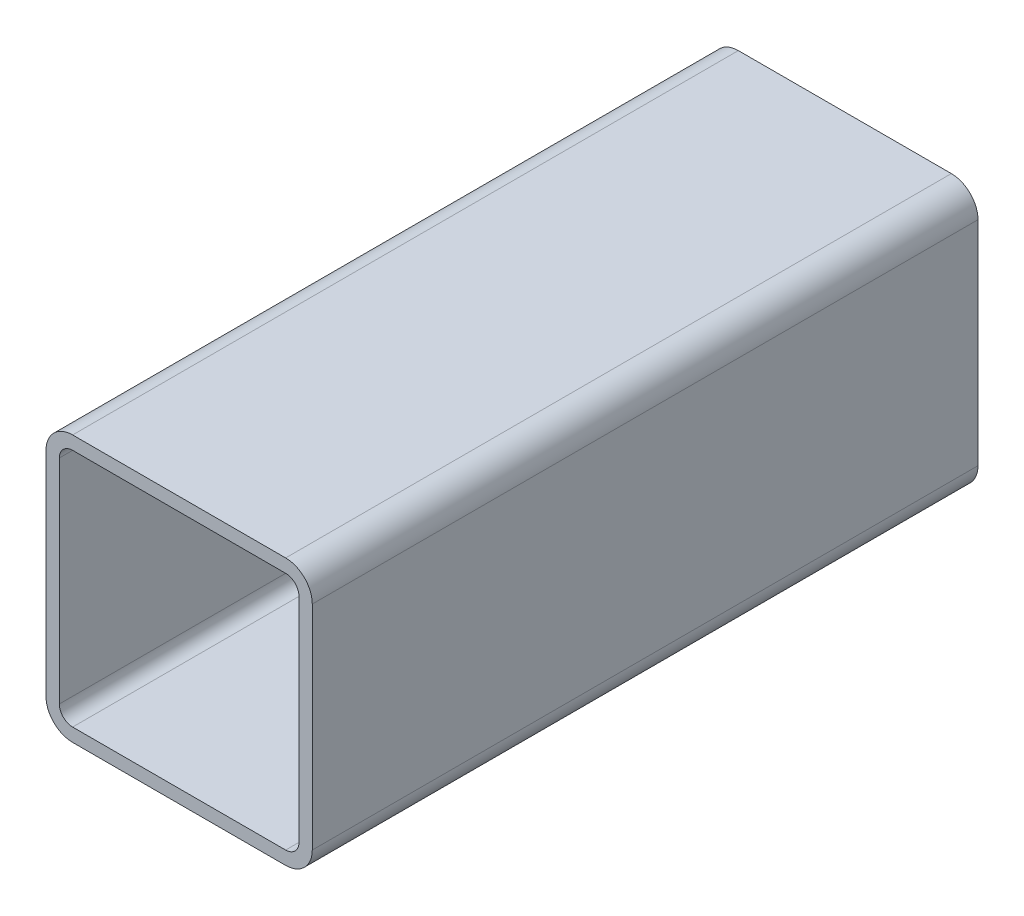
from build123d import *

# Parameters (mm, degrees)
BOSS_EXTRUDE1_DEPTH = 100
CUT_EXTRUDE1_START  = -20
SKETCH2_W           = 0.1
SKETCH2_H           = 60
CUT_EXTRUDE1_DEPTH  = 0.5
CUT_EXTRUDE2_START  = -20
CUT_EXTRUDE2_DEPTH  = 0.5


with BuildPart() as part:
    # Sketch1 → Boss-Extrude1 (new body)
    with BuildSketch(Plane.XY):
        with BuildLine():
            Line((-16, 20), (16, 20))
            ThreePointArc((16, 20), (18.828427125, 18.828427125), (20, 16))
            Line((20, 16), (20, -16))
            ThreePointArc((20, -16), (18.828427125, -18.828427125), (16, -20))
            Line((16, -20), (-16, -20))
            ThreePointArc((-16, -20), (-18.828427125, -18.828427125), (-20, -16))
            Line((-20, -16), (-20, 16))
            ThreePointArc((-20, 16), (-18.828427125, 18.828427125), (-16, 20))
        make_face()
        with BuildLine():
            Line((-18, 16), (-18, -16))
            ThreePointArc((-18, -16), (-17.414213562, -17.414213562), (-16, -18))
            Line((-16, -18), (16, -18))
            ThreePointArc((16, -18), (17.414213562, -17.414213562), (18, -16))
            Line((18, -16), (18, 16))
            ThreePointArc((18, 16), (17.414213562, 17.414213562), (16, 18))
            Line((16, 18), (-16, 18))
            ThreePointArc((-16, 18), (-17.414213562, 17.414213562), (-18, 16))
        make_face(mode=Mode.SUBTRACT)
    extrude(amount=BOSS_EXTRUDE1_DEPTH)

    # Sketch2 → Cut-Extrude1 (cut)
    with BuildSketch(Plane(origin=(0, 0, 0), x_dir=(1, 0, 0), z_dir=(0, 1, 0)).offset(CUT_EXTRUDE1_START)):
        with Locations((0.05, -50)):
            Rectangle(SKETCH2_W, SKETCH2_H)
    extrude(amount=CUT_EXTRUDE1_DEPTH, mode=Mode.SUBTRACT)

    # Sketch3 → Cut-Extrude2 (cut)
    with BuildSketch(Plane(origin=(0, 0, 0), x_dir=(1, 0, 0), z_dir=(0, 1, 0)).offset(CUT_EXTRUDE2_START)):
        Polygon((3.5, -21.813802083), (3.5, -21.166666667), (0, -21.166666667), (0, -21.480769231), (3.141025641, -21.480769231), (3.141025641, -22.019230769), align=None)
        Polygon((3.58974359, -23.679487179), (3.58974359, -23.365384615), (2.557692308, -23.365384615), (2.557692308, -22.916666667), (2.243589744, -22.916666667), (2.243589744, -23.365384615), (0, -23.365384615), (0, -23.679487179), (2.243589744, -23.679487179), (2.243589744, -24.128205128), (2.557692308, -24.128205128), (2.557692308, -23.679487179), align=None)
        with BuildLine():
            Line((2.557692308, -25.564102564), (2.557692308, -25.25))
            Line((2.557692308, -25.25), (2.181189904, -25.25))
            add(Edge.make_bspline(
                [(2.181189904, -25.25), (2.2162494, -25.226814027), (2.283300414, -25.182471034), (2.371922127, -25.108721958), (2.445625727, -25.033203416), (2.503691528, -24.954976239), (2.547533847, -24.874694376), (2.57991674, -24.793692795), (2.59874011, -24.710293521), (2.601287731, -24.654136547), (2.602564103, -24.626001603)],
                knots=[0, 0, 0, 0, 0.000126023, 0.000241017, 0.000345147, 0.000441905, 0.000532273, 0.000618856, 0.000702888, 0.000787259, 0.000787259, 0.000787259, 0.000787259], degree=3))
            add(Edge.make_bspline(
                [(2.602564103, -24.626001603), (2.60140021, -24.604168204), (2.599017547, -24.55947197), (2.581439148, -24.491605855), (2.554439176, -24.421394642), (2.52842766, -24.376085944), (2.514923878, -24.352564103)],
                knots=[0, 0, 0, 0, 6.5445e-05, 0.000133976, 0.000209232, 0.00029048, 0.00029048, 0.00029048, 0.00029048], degree=3))
            Line((2.514923878, -24.352564103), (2.242888622, -24.525040064))
            add(Edge.make_bspline(
                [(2.242888622, -24.525040064), (2.249628888, -24.540149085), (2.262423203, -24.5688289), (2.277565213, -24.610783466), (2.286481129, -24.649464803), (2.287831847, -24.674108361), (2.288461538, -24.685596955)],
                knots=[0, 0, 0, 0, 4.9621e-05, 9.4191e-05, 0.00013366, 0.000168129, 0.000168129, 0.000168129, 0.000168129], degree=3))
            add(Edge.make_bspline(
                [(2.288461538, -24.685596955), (2.286843274, -24.711055975), (2.283571966, -24.76252117), (2.256021695, -24.837971419), (2.21338135, -24.911517288), (2.164408492, -24.969182248), (2.11808863, -25.014173429), (2.077418579, -25.046297324), (2.031846108, -25.075784718), (1.982114631, -25.103953585), (1.927385308, -25.129620274), (1.868201943, -25.153574829), (1.804496858, -25.175233725), (1.760114331, -25.187583965), (1.737379808, -25.193910256)],
                knots=[0, 0, 0, 0, 7.6187e-05, 0.000154012, 0.000238193, 0.000330296, 0.000379883, 0.000431785, 0.000485456, 0.000542593, 0.000603121, 0.000666657, 0.000734059, 0.000804845, 0.000804845, 0.000804845, 0.000804845], degree=3))
            add(Edge.make_bspline(
                [(1.737379808, -25.193910256), (1.717102634, -25.19864265), (1.672190235, -25.209124541), (1.596841711, -25.219316079), (1.507818052, -25.229385597), (1.404871459, -25.236482216), (1.288259015, -25.243060258), (1.15780307, -25.24677034), (1.013369718, -25.249873481), (0.912395365, -25.249956547), (0.859575321, -25.25)],
                knots=[0, 0, 0, 0, 6.2435e-05, 0.000138289, 0.000227871, 0.000331224, 0.000447781, 0.000578258, 0.000722716, 0.000881171, 0.000881171, 0.000881171, 0.000881171], degree=3))
            Line((0.859575321, -25.25), (0, -25.25))
            Line((0, -25.25), (0, -25.564102564))
            Line((0, -25.564102564), (2.557692308, -25.564102564))
        make_face()
        with BuildLine():
            Line((2.557692308, -26.192307692), (0, -26.192307692))
            Line((0, -26.192307692), (0, -26.506410256))
            Line((0, -26.506410256), (0.442407853, -26.506410256))
            add(Edge.make_bspline(
                [(0.442407853, -26.506410256), (0.402357452, -26.541821641), (0.32419859, -26.610927403), (0.222394827, -26.726327388), (0.137553673, -26.848142506), (0.069666853, -26.976784678), (0.018284474, -27.111869012), (-0.017849104, -27.25301028), (-0.041371077, -27.400020375), (-0.04369442, -27.500276192), (-0.044871795, -27.551081731)],
                knots=[0, 0, 0, 0, 0.000160263, 0.000312755, 0.000460372, 0.00060464, 0.000748002, 0.000892888, 0.00104113, 0.001193435, 0.001193435, 0.001193435, 0.001193435], degree=3))
            add(Edge.make_bspline(
                [(-0.044871795, -27.551081731), (-0.043645626, -27.596249807), (-0.041227567, -27.685323254), (-0.022462337, -27.816350566), (0.007657479, -27.942449333), (0.049598139, -28.063699919), (0.10494392, -28.179280753), (0.171919959, -28.289843101), (0.25089654, -28.395644997), (0.341535176, -28.49467431), (0.439877501, -28.585981791), (0.545073941, -28.665866614), (0.655679624, -28.733571603), (0.771663464, -28.789212978), (0.892940677, -28.832271191), (1.019428064, -28.862228057), (1.150915158, -28.880973065), (1.240455063, -28.883389899), (1.285857372, -28.884615385)],
                knots=[0, 0, 0, 0, 0.000135464, 0.00026714, 0.000396211, 0.000523931, 0.000651257, 0.000779917, 0.000911167, 0.001046665, 0.001182119, 0.001313231, 0.001442255, 0.001570516, 0.001698468, 0.001827539, 0.00195991, 0.002096074, 0.002096074, 0.002096074, 0.002096074], degree=3))
            add(Edge.make_bspline(
                [(1.285857372, -28.884615385), (1.330321265, -28.883362718), (1.418223983, -28.880886265), (1.547499942, -28.862428635), (1.672028314, -28.831413909), (1.791347799, -28.78780574), (1.905938937, -28.732134777), (2.014905164, -28.663265415), (2.119913357, -28.583409379), (2.21759609, -28.491126052), (2.307499363, -28.391207915), (2.386667873, -28.284814067), (2.453472192, -28.173271135), (2.507777609, -28.056355459), (2.550931998, -27.934894904), (2.581014763, -27.807966801), (2.598698613, -27.676148367), (2.601263226, -27.586658815), (2.602564103, -27.541266026)],
                knots=[0, 0, 0, 0, 0.000133363, 0.00026365, 0.000390846, 0.000517716, 0.000644083, 0.000772283, 0.00090382, 0.001039238, 0.001174786, 0.001306599, 0.00143646, 0.001564122, 0.001692735, 0.001822488, 0.001954765, 0.002090929, 0.002090929, 0.002090929, 0.002090929], degree=3))
            add(Edge.make_bspline(
                [(2.602564103, -27.541266026), (2.601133352, -27.489064135), (2.598327716, -27.38669869), (2.574730898, -27.236776304), (2.5353558, -27.094818144), (2.481240021, -26.960005945), (2.409860859, -26.832862676), (2.319006253, -26.714953132), (2.210751775, -26.603903603), (2.127359309, -26.539539889), (2.084435096, -26.506410256)],
                knots=[0, 0, 0, 0, 0.00015654, 0.000306968, 0.000453936, 0.000597673, 0.000741774, 0.000889855, 0.001043054, 0.001205551, 0.001205551, 0.001205551, 0.001205551], degree=3))
            Line((2.084435096, -26.506410256), (2.557692308, -26.506410256))
            Line((2.557692308, -26.506410256), (2.557692308, -26.192307692))
        make_face()
        with BuildLine():
            add(Edge.make_bspline(
                [(2.288461538, -27.537059295), (2.286827918, -27.58297366), (2.283603412, -27.673601315), (2.258429663, -27.806644917), (2.216546024, -27.933959833), (2.159260529, -28.054900259), (2.087245119, -28.167589423), (2.000074446, -28.268205619), (1.900520567, -28.357952616), (1.787746484, -28.432153885), (1.668225935, -28.494712937), (1.542337959, -28.537612915), (1.413575056, -28.566159953), (1.326206752, -28.569058087), (1.282351763, -28.570512821)],
                knots=[0, 0, 0, 0, 0.000137677, 0.000271753, 0.000404561, 0.000538791, 0.000672205, 0.000804452, 0.00093703, 0.001072956, 0.001208416, 0.001340569, 0.001470925, 0.001602305, 0.001602305, 0.001602305, 0.001602305], degree=3))
            add(Edge.make_bspline(
                [(1.282351763, -28.570512821), (1.238767492, -28.568630736), (1.151769786, -28.564873945), (1.022624311, -28.538365394), (0.897243126, -28.492435064), (0.776066955, -28.431303929), (0.66306139, -28.355438267), (0.561560746, -28.266436112), (0.474040482, -28.164536875), (0.400785993, -28.051603279), (0.341819613, -27.931168103), (0.300239861, -27.804456462), (0.273984486, -27.673694718), (0.270820672, -27.584624152), (0.269230769, -27.539863782)],
                knots=[0, 0, 0, 0, 0.000130727, 0.000260941, 0.000393563, 0.000530272, 0.000667171, 0.000800798, 0.000934034, 0.001068799, 0.001203635, 0.001335112, 0.00146794, 0.001602119, 0.001602119, 0.001602119, 0.001602119], degree=3))
            add(Edge.make_bspline(
                [(0.269230769, -27.539863782), (0.270865873, -27.494411879), (0.274109662, -27.404242464), (0.299704414, -27.270885724), (0.341067285, -27.141270791), (0.399172696, -27.017325728), (0.470855123, -26.901947277), (0.555144025, -26.798525169), (0.652350119, -26.710214367), (0.760039451, -26.636182114), (0.877544377, -26.577700344), (1.003184173, -26.536452396), (1.135971494, -26.511118449), (1.226849293, -26.508001354), (1.273237179, -26.506410256)],
                knots=[0, 0, 0, 0, 0.000136278, 0.000270353, 0.00040583, 0.00054353, 0.000679905, 0.000812408, 0.000942435, 0.001072538, 0.001203289, 0.001334766, 0.001468152, 0.001607229, 0.001607229, 0.001607229, 0.001607229], degree=3))
            add(Edge.make_bspline(
                [(1.273237179, -26.506410256), (1.308574996, -26.507369928), (1.378131003, -26.509258865), (1.480258715, -26.523689218), (1.577991728, -26.546644938), (1.671437013, -26.57898822), (1.760062376, -26.621490241), (1.844562515, -26.672697546), (1.924150324, -26.733660474), (1.998725013, -26.802523767), (2.066404356, -26.878750798), (2.126056362, -26.959808365), (2.176538373, -27.04549253), (2.216937187, -27.135743146), (2.249849087, -27.229865098), (2.271586828, -27.328760526), (2.286560777, -27.431432745), (2.28782128, -27.501479732), (2.288461538, -27.537059295)],
                knots=[0, 0, 0, 0, 0.000105983, 0.000208608, 0.000308773, 0.00040678, 0.000504626, 0.000603105, 0.000702667, 0.000804872, 0.000907174, 0.001008001, 0.001106363, 0.00120489, 0.001304222, 0.001404911, 0.00150823, 0.001614884, 0.001614884, 0.001614884, 0.001614884], degree=3))
        make_face(mode=Mode.SUBTRACT)
        with BuildLine():
            Line((3.5, -31.576923077), (3.5, -30.89052484))
            add(Edge.make_bspline(
                [(3.5, -30.89052484), (3.499948104, -30.843313934), (3.499848668, -30.752855741), (3.496833922, -30.623140685), (3.49280723, -30.505330953), (3.487225337, -30.399680573), (3.480628747, -30.305864474), (3.471376708, -30.224307175), (3.461716412, -30.154367619), (3.451895005, -30.112461169), (3.447415865, -30.093349359)],
                knots=[0, 0, 0, 0, 0.000141628, 0.000271366, 0.00038923, 0.000495248, 0.00058876, 0.000671296, 0.000741499, 0.00080036, 0.00080036, 0.00080036, 0.00080036], degree=3))
            add(Edge.make_bspline(
                [(3.447415865, -30.093349359), (3.440793975, -30.069155768), (3.42770623, -30.021338678), (3.401491651, -29.952438461), (3.370412659, -29.886881548), (3.334976989, -29.82446133), (3.293734792, -29.765877322), (3.247990678, -29.710379612), (3.197769812, -29.657649879), (3.142098627, -29.609479336), (3.083029703, -29.565132167), (3.019247543, -29.527089024), (2.952140341, -29.494909547), (2.881020836, -29.468628716), (2.806321276, -29.448645146), (2.727823588, -29.433880654), (2.645797497, -29.424434148), (2.589736435, -29.423534764), (2.561197917, -29.423076923)],
                knots=[0, 0, 0, 0, 7.5216e-05, 0.00014866, 0.000220794, 0.000292713, 0.000363707, 0.000435434, 0.000508327, 0.000581868, 0.000656048, 0.000729635, 0.000804271, 0.000879029, 0.000956755, 0.00103596, 0.001118496, 0.001204079, 0.001204079, 0.001204079, 0.001204079], degree=3))
            add(Edge.make_bspline(
                [(2.561197917, -29.423076923), (2.53242014, -29.423498348), (2.476114476, -29.424322894), (2.393741688, -29.434219179), (2.315023298, -29.447549371), (2.240133847, -29.468046423), (2.169518077, -29.494892096), (2.102096845, -29.526384149), (2.039017173, -29.564367679), (1.980050055, -29.608012509), (1.925140143, -29.656564103), (1.874685348, -29.709817042), (1.82898101, -29.767556334), (1.787924666, -29.829598482), (1.752468387, -29.896548331), (1.720711082, -29.967390485), (1.694040021, -30.042740701), (1.68000996, -30.094883215), (1.672876603, -30.121394231)],
                knots=[0, 0, 0, 0, 8.6284e-05, 0.00016882, 0.000248587, 0.000325638, 0.000401297, 0.000474998, 0.000548586, 0.000621785, 0.0006948, 0.0007682, 0.000841564, 0.000915458, 0.000991056, 0.00106858, 0.00114819, 0.001230532, 0.001230532, 0.001230532, 0.001230532], degree=3))
            add(Edge.make_bspline(
                [(1.672876603, -30.121394231), (1.668213621, -30.143321565), (1.657994427, -30.191376592), (1.64658597, -30.270519314), (1.63684837, -30.3626647), (1.629547232, -30.46768698), (1.623296864, -30.585491885), (1.61832877, -30.716143142), (1.615598916, -30.85989722), (1.615458123, -30.960168464), (1.615384615, -31.012520032)],
                knots=[0, 0, 0, 0, 6.7238e-05, 0.000147357, 0.000239727, 0.000345177, 0.000463135, 0.000593636, 0.000737393, 0.000894446, 0.000894446, 0.000894446, 0.000894446], degree=3))
            Line((1.615384615, -31.012520032), (1.615384615, -31.262820513))
            Line((1.615384615, -31.262820513), (0, -31.262820513))
            Line((0, -31.262820513), (0, -31.576923077))
            Line((0, -31.576923077), (3.5, -31.576923077))
        make_face()
        with BuildLine():
            Line((3.141025641, -31.262820513), (1.974358974, -31.262820513))
            Line((1.974358974, -31.262820513), (1.966646635, -30.650040064))
            add(Edge.make_bspline(
                [(1.966646635, -30.650040064), (1.966627924, -30.620119846), (1.966591804, -30.562359481), (1.970631709, -30.478694151), (1.975087995, -30.401271153), (1.982066731, -30.329922351), (1.99126187, -30.265192997), (2.001270604, -30.206251665), (2.014830447, -30.153961225), (2.033737491, -30.092686403), (2.065355346, -30.024639307), (2.112432024, -29.951102776), (2.170792088, -29.887772834), (2.237310672, -29.833335994), (2.311578922, -29.791147588), (2.390418136, -29.759416527), (2.473877922, -29.740933367), (2.530961719, -29.738439287), (2.559795673, -29.737179487)],
                knots=[0, 0, 0, 0, 8.9746e-05, 0.000173253, 0.000251233, 0.000322392, 0.00038823, 0.000447366, 0.000501611, 0.000550171, 0.000639588, 0.000725738, 0.000811102, 0.00089684, 0.000982586, 0.001066302, 0.001151019, 0.001237488, 0.001237488, 0.001237488, 0.001237488], degree=3))
            add(Edge.make_bspline(
                [(2.559795673, -29.737179487), (2.587932, -29.738446014), (2.643863535, -29.740963714), (2.725874557, -29.759562321), (2.803877317, -29.791085645), (2.877231232, -29.833621869), (2.943477588, -29.886495654), (3.000520555, -29.948422145), (3.047000556, -30.018136845), (3.076793746, -30.083020031), (3.095014888, -30.140616102), (3.107758306, -30.190649302), (3.117934363, -30.247139584), (3.126173726, -30.310107484), (3.133227231, -30.379064281), (3.138013195, -30.454602607), (3.140814655, -30.536436247), (3.14095361, -30.593246818), (3.141025641, -30.622696314)],
                knots=[0, 0, 0, 0, 8.4371e-05, 0.000167719, 0.000250783, 0.000335923, 0.000421221, 0.000504087, 0.000587508, 0.000671588, 0.000717263, 0.000768617, 0.000826374, 0.000889338, 0.000959102, 0.001034283, 0.001116362, 0.001204706, 0.001204706, 0.001204706, 0.001204706], degree=3))
            Line((3.141025641, -30.622696314), (3.141025641, -31.262820513))
        make_face(mode=Mode.SUBTRACT)
    extrude(amount=CUT_EXTRUDE2_DEPTH, mode=Mode.SUBTRACT)


solid = part.part
